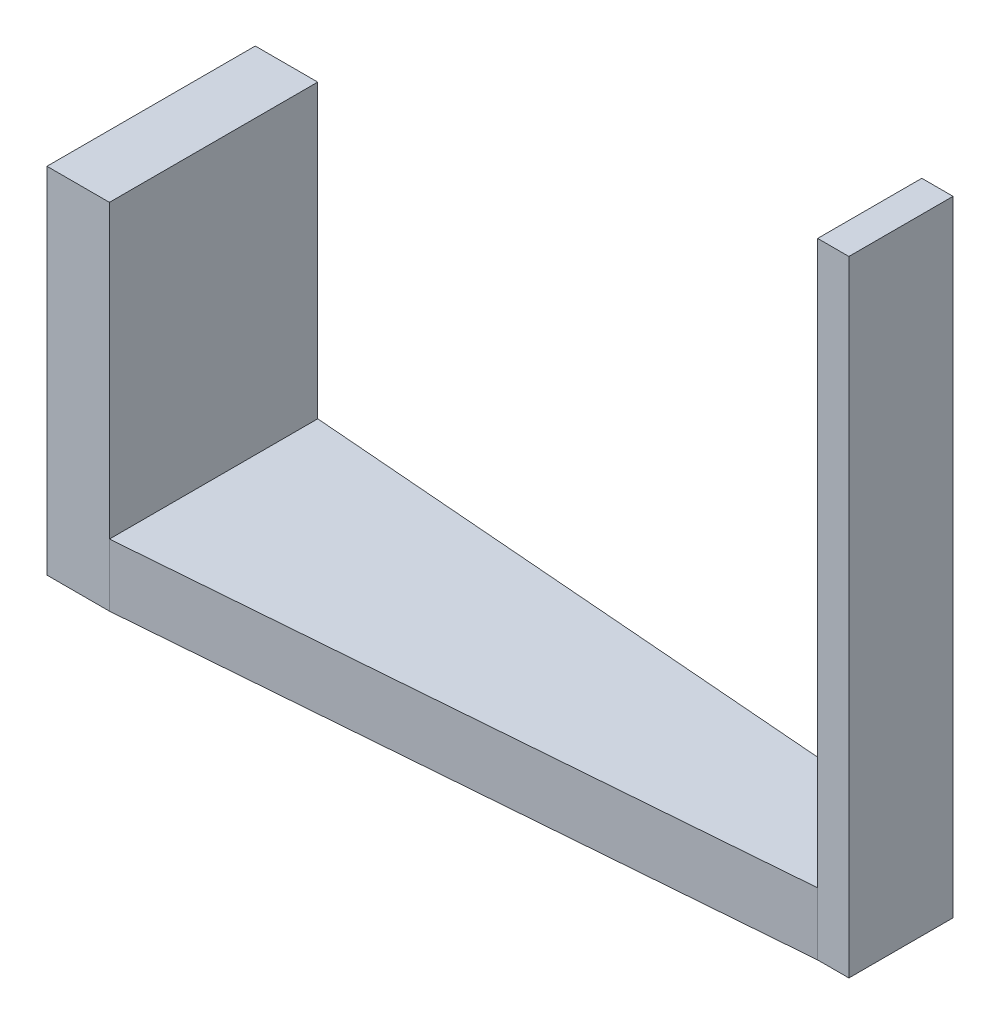
from build123d import *

# Parameters (mm, degrees)
BOSS_EXTRUDE1_DEPTH = 3
SKETCH2_W           = 3
SKETCH2_H           = 10
BOSS_EXTRUDE2_DEPTH = 14
SKETCH3_W           = 1.5
SKETCH3_H           = 5
BOSS_EXTRUDE3_DEPTH = 27


with BuildPart() as part:
    # Sketch1 → Boss-Extrude1 (new body)
    with BuildSketch(Plane(origin=(0, 0, 0), x_dir=(1, 0, 0), z_dir=(0, 1, 0))):
        Polygon((18, 2.5), (16.5, 2.5), (-15, 5), (-18, 5), (-18, -5), (-15, -5), (16.5, -2.5), (18, -2.5), align=None)
    extrude(amount=BOSS_EXTRUDE1_DEPTH)

    # Sketch2 → Boss-Extrude2 (add)
    with BuildSketch(Plane(origin=(0, 3, 0), x_dir=(1, 0, 0), z_dir=(0, 1, 0))):
        with Locations((-16.5, 0)):
            Rectangle(SKETCH2_W, SKETCH2_H)
    extrude(amount=BOSS_EXTRUDE2_DEPTH)

    # Sketch3 → Boss-Extrude3 (add)
    with BuildSketch(Plane(origin=(0, 3, 0), x_dir=(1, 0, 0), z_dir=(0, 1, 0))):
        with Locations((17.25, 0)):
            Rectangle(SKETCH3_W, SKETCH3_H)
    extrude(amount=BOSS_EXTRUDE3_DEPTH)


solid = part.part
